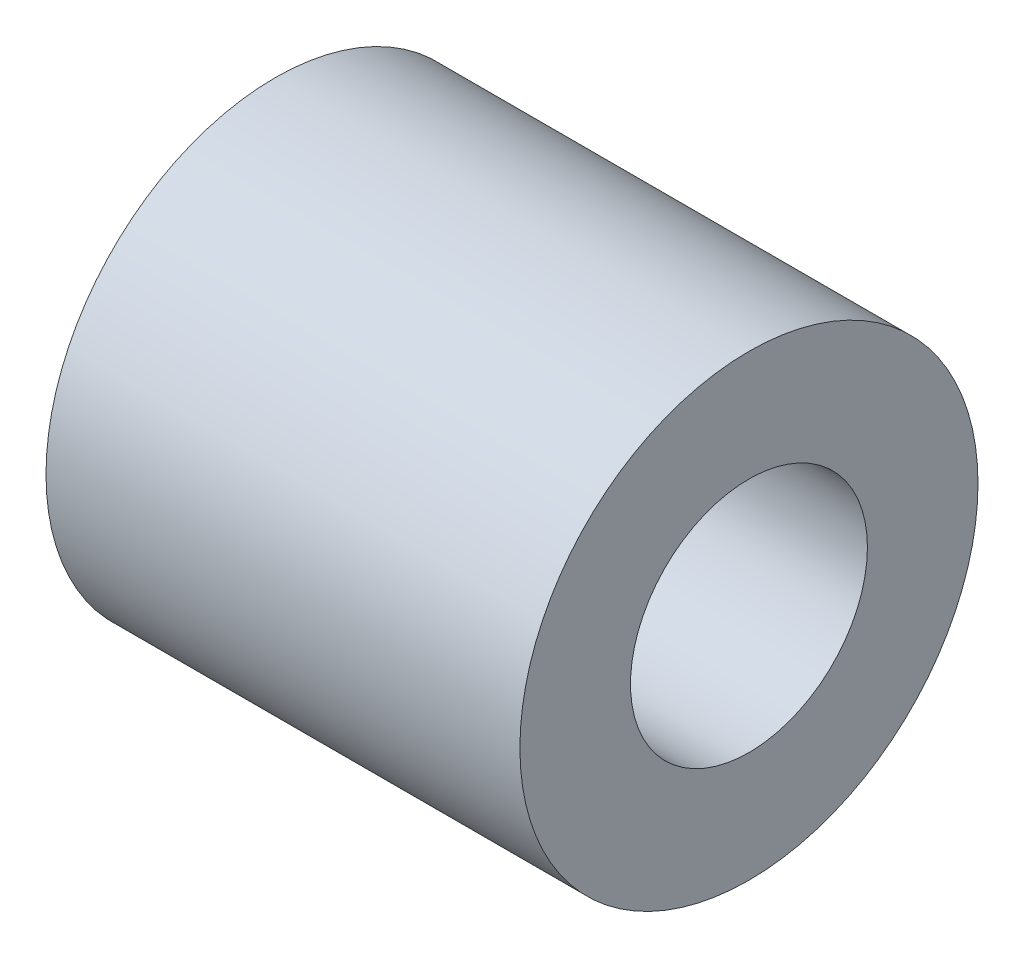
from build123d import *

# Parameters (mm, degrees)
ESQUISSE1_R      = 2.9
ESQUISSE1_R_2    = 1.5
EXTRUSION1_DEPTH = 6


with BuildPart() as part:
    # Esquisse1 → Extrusion1 (new body)
    with BuildSketch(Plane(origin=(0, 0, 0), x_dir=(0, 0, -1), z_dir=(1, 0, 0))):
        Circle(ESQUISSE1_R)
        Circle(ESQUISSE1_R_2, mode=Mode.SUBTRACT)
    extrude(amount=EXTRUSION1_DEPTH)


solid = part.part
